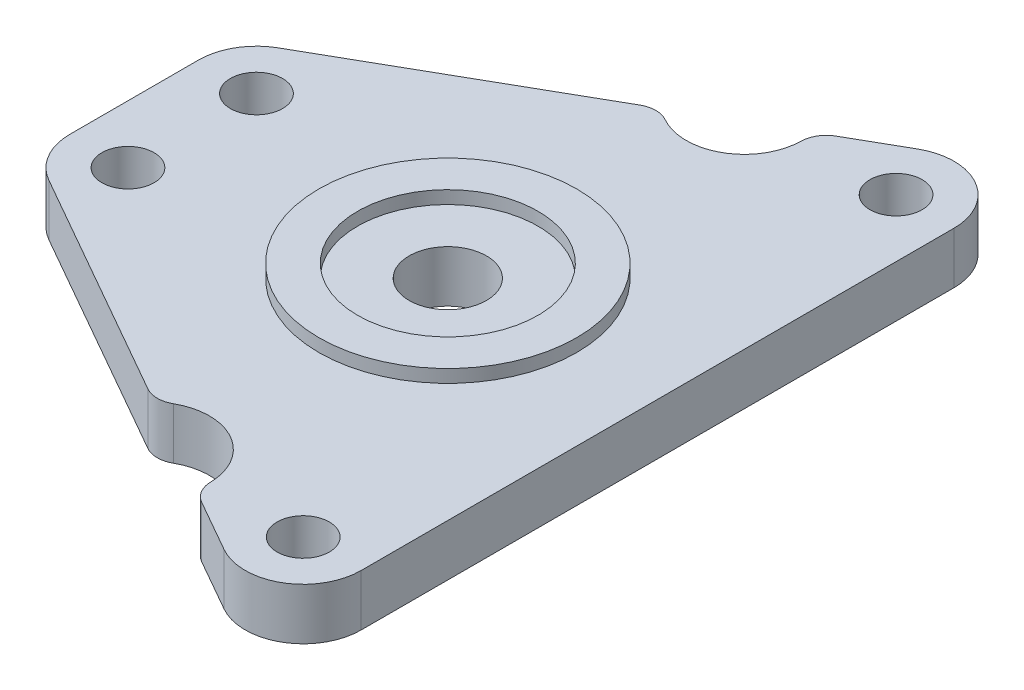
from build123d import *

# Parameters (mm, degrees)
SKETCH1_R           = 2.025
SKETCH1_R_2         = 3
BOSS_EXTRUDE1_DEPTH = 4
SKETCH2_R           = 10
SKETCH2_R_2         = 7
BOSS_EXTRUDE2_DEPTH = 1
FILLET1_R           = 2


with BuildPart() as part:
    # Sketch1 → Boss-Extrude1 (new body)
    with BuildSketch(Plane(origin=(0, 0, 0), x_dir=(1, 0, 0), z_dir=(0, 1, 0))):
        with BuildLine():
            Line((2.27183836, -8.894641378), (21.255729613, -19.713837864))
            ThreePointArc((21.255729613, -19.713837864), (26.55816164, -19.090358622), (28.724166028, -23.970208697))
            Line((28.724166028, -23.970208697), (33.88183836, -26.909641378))
            ThreePointArc((33.88183836, -26.909641378), (38.370892813, -26.890805018), (40.61, -23))
            Line((40.61, -23), (40.61, 23))
            ThreePointArc((40.61, 23), (38.370892813, 26.890805018), (33.88183836, 26.909641378))
            Line((33.88183836, 26.909641378), (28.724166028, 23.970208697))
            ThreePointArc((28.724166028, 23.970208697), (26.55816164, 19.090358622), (21.255729613, 19.713837864))
            Line((21.255729613, 19.713837864), (2.27183836, 8.894641378))
            ThreePointArc((2.27183836, 8.894641378), (0.609194982, 7.245892813), (0, 4.985))
            Line((0, 4.985), (0, -4.985))
            ThreePointArc((0, -4.985), (0.609194982, -7.245892813), (2.27183836, -8.894641378))
        make_face()
        with Locations((36.11, -23)):
            Circle(SKETCH1_R, mode=Mode.SUBTRACT)
        with Locations((36.11, 23)):
            Circle(SKETCH1_R, mode=Mode.SUBTRACT)
        with Locations((4.5, 4.985)):
            Circle(SKETCH1_R, mode=Mode.SUBTRACT)
        with Locations((4.5, -4.985)):
            Circle(SKETCH1_R, mode=Mode.SUBTRACT)
        with Locations((24.33, 0)):
            Circle(SKETCH1_R_2, mode=Mode.SUBTRACT)
    extrude(amount=BOSS_EXTRUDE1_DEPTH)

    # Sketch2 → Boss-Extrude2 (add)
    with BuildSketch(Plane(origin=(0, 4, 0), x_dir=(1, 0, 0), z_dir=(0, 1, 0))):
        with Locations((24.33, 0)):
            Circle(SKETCH2_R)
        with Locations((24.33, 0)):
            Circle(SKETCH2_R_2, mode=Mode.SUBTRACT)
    extrude(amount=BOSS_EXTRUDE2_DEPTH)

    # Fillet1
    fillet1_edges = [part.edges().sort_by_distance(p)[0] for p in [
        (21.255729613, 2, -19.713837864),
        (28.724166028, 2, -23.970208697),
        (28.724166028, 2, 23.970208697),
        (21.255729613, 2, 19.713837864),
    ]]
    fillet(fillet1_edges, radius=FILLET1_R)


solid = part.part
